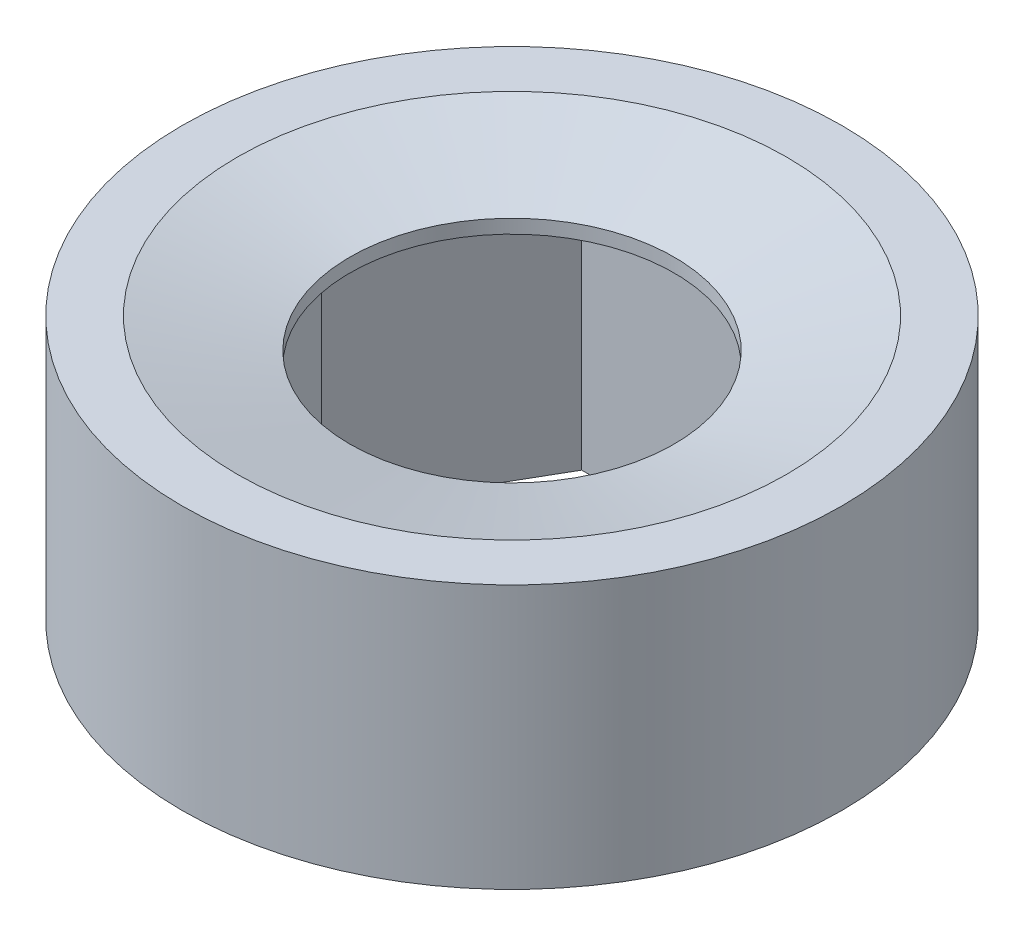
from build123d import *

# Parameters (mm, degrees)
SKETCH1_R           = 12
BOSS_EXTRUDE1_DEPTH = 8
SKETCH2_R           = 12
SKETCH2_R_2         = 5.9
BOSS_EXTRUDE2_DEPTH = 1.6
SKETCH3_R           = 10
CUT_EXTRUDE1_DEPTH  = 1.1
CUT_EXTRUDE1_DRAFT  = -75


with BuildPart() as part:
    # Sketch1 → Boss-Extrude1 (new body)
    with BuildSketch(Plane(origin=(0, 0, 0), x_dir=(1, 0, 0), z_dir=(0, 1, 0))):
        Circle(SKETCH1_R)
        Polygon((3.464101615, 6), (-3.464101615, 6), (-6.92820323, 0), (-3.464101615, -6), (3.464101615, -6), (6.92820323, 0), align=None, mode=Mode.SUBTRACT)
    extrude(amount=BOSS_EXTRUDE1_DEPTH)

    # Sketch2 → Boss-Extrude2 (add)
    with BuildSketch(Plane(origin=(0, 8, 0), x_dir=(1, 0, 0), z_dir=(0, 1, 0))):
        Circle(SKETCH2_R)
        Circle(SKETCH2_R_2, mode=Mode.SUBTRACT)
    extrude(amount=BOSS_EXTRUDE2_DEPTH)


with BuildPart() as cut_extrude1_tool:
    # Sketch3 → Cut-Extrude1 (with draft: the straight prism first)
    with BuildSketch(Plane(origin=(0, 9.6, 0), x_dir=(1, 0, 0), z_dir=(0, 1, 0))):
        Circle(SKETCH3_R)
    extrude(amount=-CUT_EXTRUDE1_DEPTH)
    # Cut-Extrude1: the draft: its side faces are tilted about the plane it starts from
    cut_extrude1_sides = [cut_extrude1_tool.faces().sort_by_distance(p)[0] for p in [
        (-10, 9.05, 0),
    ]]
    draft(cut_extrude1_sides, Plane(origin=(0, 9.6, 0), x_dir=(1, 0, 0), z_dir=(0, 1, 0)), CUT_EXTRUDE1_DRAFT)


with BuildPart() as part_1:
    add(part.part)

    # Cut-Extrude1: cut by cut_extrude1_tool
    add(cut_extrude1_tool.part, mode=Mode.SUBTRACT)


solid = part_1.part
